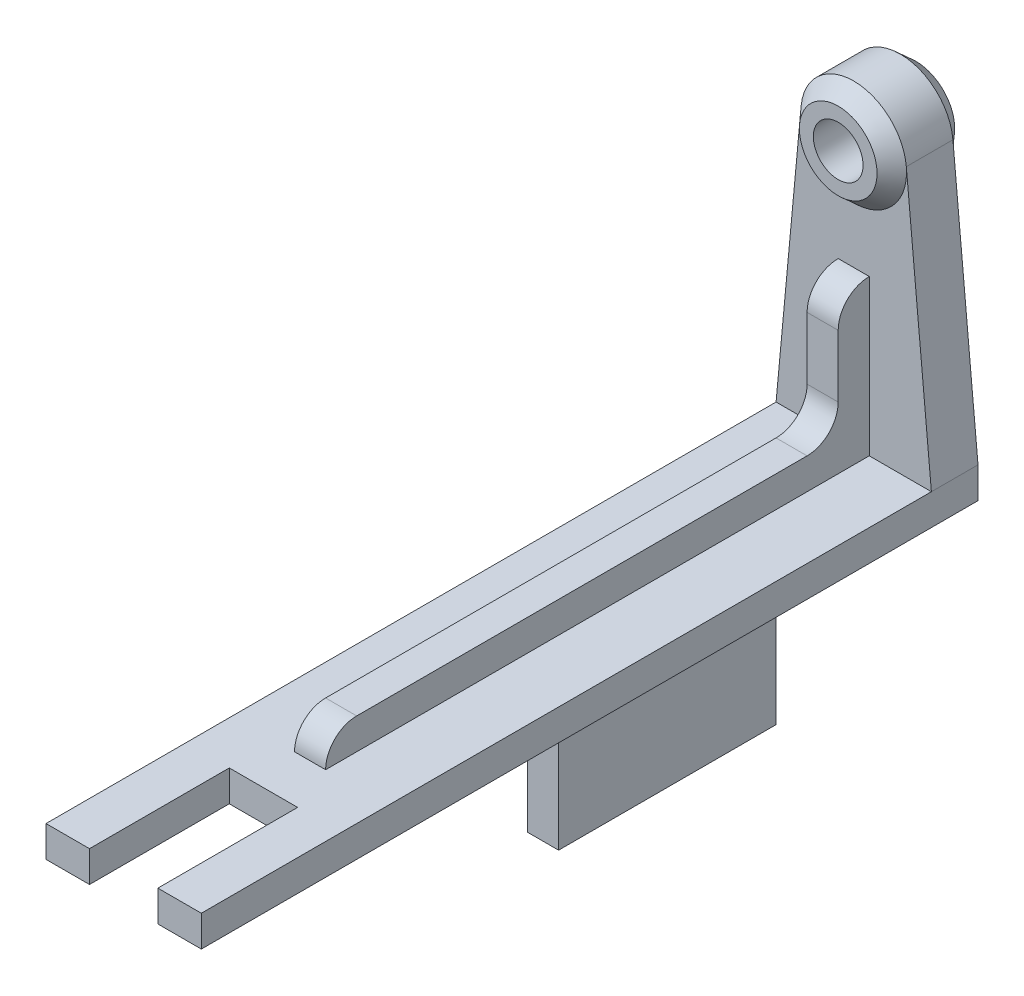
from build123d import *

# Parameters (mm, degrees)
BOSS_EXTRUDE1_DEPTH = 7.5
SKETCH2_W           = 50
SKETCH2_H           = 10
BOSS_EXTRUDE2_DEPTH = 235
SKETCH4_W           = 70
SKETCH4_H           = 49.933850778
BOSS_EXTRUDE3_DEPTH = 5
SKETCH5_R           = 8
CUT_EXTRUDE1_DEPTH  = 21
SKETCH6_W           = 67.307350871
SKETCH6_H           = 68.73953257
CUT_EXTRUDE2_DEPTH  = 11


with BuildPart() as part:
    # Sketch1 → Boss-Extrude1 (new body, symmetric)
    with BuildSketch(Plane.XY):
        with BuildLine():
            Line((-25, -85), (-16.926566325, 1.57840186))
            ThreePointArc((-16.926566325, 1.57840186), (0, 17), (16.926566325, 1.57840186))
            Line((16.926566325, 1.57840186), (25, -85))
            Line((25, -85), (25, -95))
            Line((25, -95), (-25, -95))
            Line((-25, -95), (-25, -85))
        make_face()
    extrude(amount=BOSS_EXTRUDE1_DEPTH, both=True)

    # Sketch2 → Boss-Extrude2 (add)
    with BuildSketch(Plane.XY.offset(7.5)):
        with Locations((0, -90)):
            Rectangle(SKETCH2_W, SKETCH2_H)
    extrude(amount=BOSS_EXTRUDE2_DEPTH)

    # Sketch3 → Revolve1 (revolve)
    with BuildSketch(Plane(origin=(0, 0, 0), x_dir=(0, 0, -1), z_dir=(1, 0, 0)), mode=Mode.PRIVATE) as revolve1_sk:
        Polygon((-12.5, 8), (-12.5, 12.5), (-7.5, 17), (-7.5, 8), align=None)
        Polygon((12.5, 8), (7.5, 8), (7.5, 17), (12.5, 12.5), align=None)
    revolve(revolve1_sk.sketch.rotate(Axis((0, 0, 1025), (0, 0, -1)), 90), axis=Axis((0, 0, 1025), (0, 0, -1)))  # turned: the seam where the file's is

    # Sketch4 → Boss-Extrude3 (add, symmetric)
    with BuildSketch(Plane(origin=(0, 0, 0), x_dir=(0, 0, -1), z_dir=(1, 0, 0))):
        with BuildLine():
            Line((-17.509416808, -45), (-17.509416808, -65))
            ThreePointArc((-17.509416808, -65), (-20.438348996, -72.071067812), (-27.509416808, -75))
            Line((-27.509416808, -75), (-172.5, -75))
            ThreePointArc((-172.5, -75), (-179.571067812, -77.928932188), (-182.5, -85))
            Line((-182.5, -85), (-7.5, -85))
            Line((-7.5, -85), (-7.5, -35))
            Line((-7.5, -35), (-7.509416808, -35))
            ThreePointArc((-7.509416808, -35), (-14.58048462, -37.928932188), (-17.509416808, -45))
        make_face()
        with Locations((-72.5, -119.966925389)):
            Rectangle(SKETCH4_W, SKETCH4_H)
    extrude(amount=BOSS_EXTRUDE3_DEPTH, both=True)

    # Sketch5 → Cut-Extrude1 (cut, through all)
    with BuildSketch(Plane.XY.offset(7.5)):
        Circle(SKETCH5_R)
    extrude(amount=-CUT_EXTRUDE1_DEPTH, mode=Mode.SUBTRACT)

    # Sketch6 → Cut-Extrude2 (cut, symmetric)
    with BuildSketch(Plane(origin=(0, 0, 0), x_dir=(0, 0, -1), z_dir=(1, 0, 0))):
        with Locations((-231.153675436, -92.172536307)):
            Rectangle(SKETCH6_W, SKETCH6_H)
    extrude(amount=CUT_EXTRUDE2_DEPTH, both=True, mode=Mode.SUBTRACT)


solid = part.part
